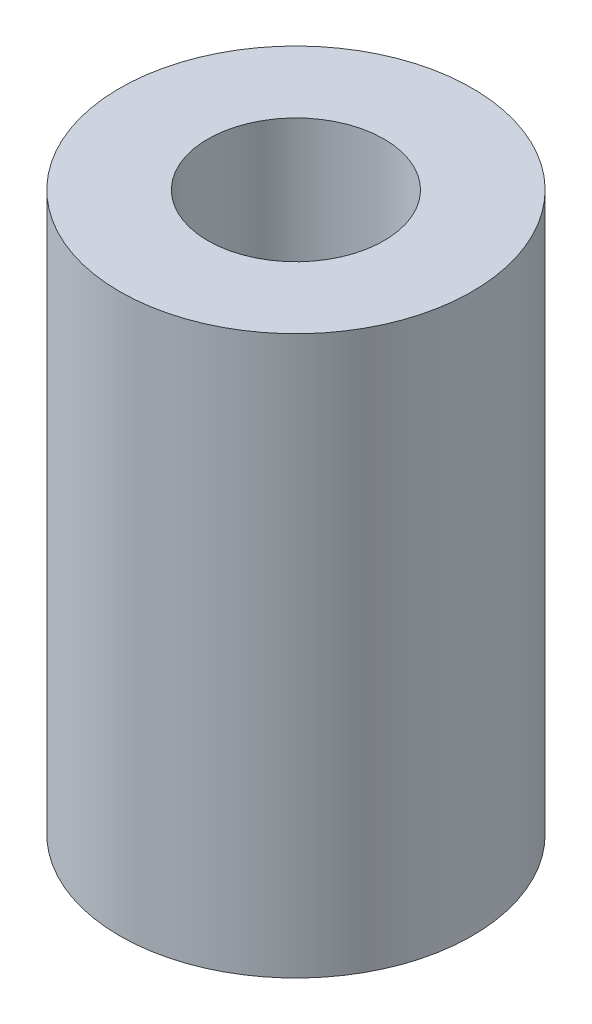
from build123d import *

# Parameters (mm, degrees)
SKETCH1_R           = 6
SKETCH1_R_2         = 3
BOSS_EXTRUDE1_DEPTH = 19


with BuildPart() as part:
    # Sketch1 → Boss-Extrude1 (new body)
    with BuildSketch(Plane(origin=(0, 0, 0), x_dir=(1, 0, 0), z_dir=(0, 1, 0))):
        Circle(SKETCH1_R)
        Circle(SKETCH1_R_2, mode=Mode.SUBTRACT)
    extrude(amount=BOSS_EXTRUDE1_DEPTH)


solid = part.part
